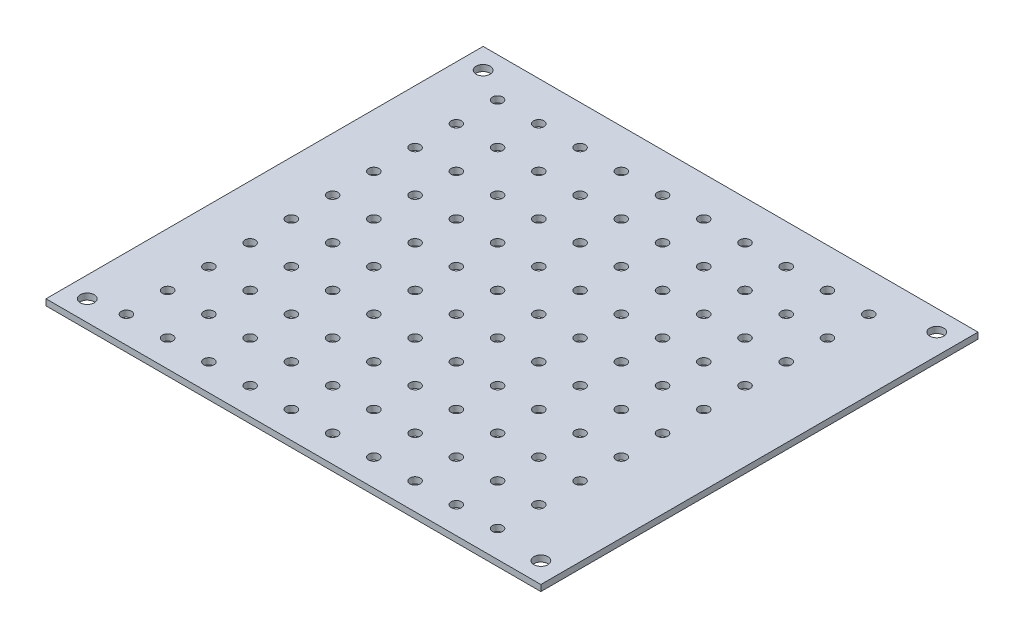
from build123d import *

# Parameters (mm, degrees)
SKETCH1_W           = 120
SKETCH1_H           = 106
SKETCH1_R           = 1.25
SKETCH1_R_2         = 1.7
BOSS_EXTRUDE1_DEPTH = 1.5


with BuildPart() as part:
    # Sketch1 → Boss-Extrude1 (new body)
    with BuildSketch(Plane(origin=(0, 0, 0), x_dir=(1, 0, 0), z_dir=(0, 1, 0))):
        with Locations((60, 53)):
            Rectangle(SKETCH1_W, SKETCH1_H)
        with Locations((13, 36.5)):
            Circle(SKETCH1_R, mode=Mode.SUBTRACT)
        with Locations((23, 36.5)):
            Circle(SKETCH1_R, mode=Mode.SUBTRACT)
        with Locations((13, 6.5)):
            Circle(SKETCH1_R, mode=Mode.SUBTRACT)
        with Locations((5, 5)):
            Circle(SKETCH1_R_2, mode=Mode.SUBTRACT)
        with Locations((5, 101)):
            Circle(SKETCH1_R_2, mode=Mode.SUBTRACT)
        with Locations((115, 101)):
            Circle(SKETCH1_R_2, mode=Mode.SUBTRACT)
        with Locations((115, 5)):
            Circle(SKETCH1_R_2, mode=Mode.SUBTRACT)
        with Locations((23, 6.5)):
            Circle(SKETCH1_R, mode=Mode.SUBTRACT)
        with Locations((33, 6.5)):
            Circle(SKETCH1_R, mode=Mode.SUBTRACT)
        with Locations((23, 16.5)):
            Circle(SKETCH1_R, mode=Mode.SUBTRACT)
        with Locations((33, 16.5)):
            Circle(SKETCH1_R, mode=Mode.SUBTRACT)
        with Locations((23, 26.5)):
            Circle(SKETCH1_R, mode=Mode.SUBTRACT)
        with Locations((33, 26.5)):
            Circle(SKETCH1_R, mode=Mode.SUBTRACT)
        with Locations((13, 16.5)):
            Circle(SKETCH1_R, mode=Mode.SUBTRACT)
        with Locations((13, 26.5)):
            Circle(SKETCH1_R, mode=Mode.SUBTRACT)
        with Locations((33, 36.5)):
            Circle(SKETCH1_R, mode=Mode.SUBTRACT)
        with Locations((13, 46.5)):
            Circle(SKETCH1_R, mode=Mode.SUBTRACT)
        with Locations((23, 46.5)):
            Circle(SKETCH1_R, mode=Mode.SUBTRACT)
        with Locations((33, 46.5)):
            Circle(SKETCH1_R, mode=Mode.SUBTRACT)
        with Locations((13, 56.5)):
            Circle(SKETCH1_R, mode=Mode.SUBTRACT)
        with Locations((23, 56.5)):
            Circle(SKETCH1_R, mode=Mode.SUBTRACT)
        with Locations((33, 56.5)):
            Circle(SKETCH1_R, mode=Mode.SUBTRACT)
        with Locations((13, 66.5)):
            Circle(SKETCH1_R, mode=Mode.SUBTRACT)
        with Locations((23, 66.5)):
            Circle(SKETCH1_R, mode=Mode.SUBTRACT)
        with Locations((33, 66.5)):
            Circle(SKETCH1_R, mode=Mode.SUBTRACT)
        with Locations((13, 76.5)):
            Circle(SKETCH1_R, mode=Mode.SUBTRACT)
        with Locations((23, 76.5)):
            Circle(SKETCH1_R, mode=Mode.SUBTRACT)
        with Locations((33, 76.5)):
            Circle(SKETCH1_R, mode=Mode.SUBTRACT)
        with Locations((13, 86.5)):
            Circle(SKETCH1_R, mode=Mode.SUBTRACT)
        with Locations((23, 86.5)):
            Circle(SKETCH1_R, mode=Mode.SUBTRACT)
        with Locations((33, 86.5)):
            Circle(SKETCH1_R, mode=Mode.SUBTRACT)
        with Locations((13, 96.5)):
            Circle(SKETCH1_R, mode=Mode.SUBTRACT)
        with Locations((23, 96.5)):
            Circle(SKETCH1_R, mode=Mode.SUBTRACT)
        with Locations((33, 96.5)):
            Circle(SKETCH1_R, mode=Mode.SUBTRACT)
        with Locations((43, 6.5)):
            Circle(SKETCH1_R, mode=Mode.SUBTRACT)
        with Locations((53, 6.5)):
            Circle(SKETCH1_R, mode=Mode.SUBTRACT)
        with Locations((63, 6.5)):
            Circle(SKETCH1_R, mode=Mode.SUBTRACT)
        with Locations((73, 6.5)):
            Circle(SKETCH1_R, mode=Mode.SUBTRACT)
        with Locations((83, 6.5)):
            Circle(SKETCH1_R, mode=Mode.SUBTRACT)
        with Locations((93, 6.5)):
            Circle(SKETCH1_R, mode=Mode.SUBTRACT)
        with Locations((103, 6.5)):
            Circle(SKETCH1_R, mode=Mode.SUBTRACT)
        with Locations((43, 16.5)):
            Circle(SKETCH1_R, mode=Mode.SUBTRACT)
        with Locations((53, 16.5)):
            Circle(SKETCH1_R, mode=Mode.SUBTRACT)
        with Locations((63, 16.5)):
            Circle(SKETCH1_R, mode=Mode.SUBTRACT)
        with Locations((73, 16.5)):
            Circle(SKETCH1_R, mode=Mode.SUBTRACT)
        with Locations((83, 16.5)):
            Circle(SKETCH1_R, mode=Mode.SUBTRACT)
        with Locations((93, 16.5)):
            Circle(SKETCH1_R, mode=Mode.SUBTRACT)
        with Locations((103, 16.5)):
            Circle(SKETCH1_R, mode=Mode.SUBTRACT)
        with Locations((43, 26.5)):
            Circle(SKETCH1_R, mode=Mode.SUBTRACT)
        with Locations((53, 26.5)):
            Circle(SKETCH1_R, mode=Mode.SUBTRACT)
        with Locations((63, 26.5)):
            Circle(SKETCH1_R, mode=Mode.SUBTRACT)
        with Locations((73, 26.5)):
            Circle(SKETCH1_R, mode=Mode.SUBTRACT)
        with Locations((83, 26.5)):
            Circle(SKETCH1_R, mode=Mode.SUBTRACT)
        with Locations((93, 26.5)):
            Circle(SKETCH1_R, mode=Mode.SUBTRACT)
        with Locations((103, 26.5)):
            Circle(SKETCH1_R, mode=Mode.SUBTRACT)
        with Locations((43, 36.5)):
            Circle(SKETCH1_R, mode=Mode.SUBTRACT)
        with Locations((53, 36.5)):
            Circle(SKETCH1_R, mode=Mode.SUBTRACT)
        with Locations((63, 36.5)):
            Circle(SKETCH1_R, mode=Mode.SUBTRACT)
        with Locations((73, 36.5)):
            Circle(SKETCH1_R, mode=Mode.SUBTRACT)
        with Locations((83, 36.5)):
            Circle(SKETCH1_R, mode=Mode.SUBTRACT)
        with Locations((93, 36.5)):
            Circle(SKETCH1_R, mode=Mode.SUBTRACT)
        with Locations((103, 36.5)):
            Circle(SKETCH1_R, mode=Mode.SUBTRACT)
        with Locations((43, 46.5)):
            Circle(SKETCH1_R, mode=Mode.SUBTRACT)
        with Locations((53, 46.5)):
            Circle(SKETCH1_R, mode=Mode.SUBTRACT)
        with Locations((63, 46.5)):
            Circle(SKETCH1_R, mode=Mode.SUBTRACT)
        with Locations((73, 46.5)):
            Circle(SKETCH1_R, mode=Mode.SUBTRACT)
        with Locations((83, 46.5)):
            Circle(SKETCH1_R, mode=Mode.SUBTRACT)
        with Locations((93, 46.5)):
            Circle(SKETCH1_R, mode=Mode.SUBTRACT)
        with Locations((103, 46.5)):
            Circle(SKETCH1_R, mode=Mode.SUBTRACT)
        with Locations((43, 56.5)):
            Circle(SKETCH1_R, mode=Mode.SUBTRACT)
        with Locations((53, 56.5)):
            Circle(SKETCH1_R, mode=Mode.SUBTRACT)
        with Locations((63, 56.5)):
            Circle(SKETCH1_R, mode=Mode.SUBTRACT)
        with Locations((73, 56.5)):
            Circle(SKETCH1_R, mode=Mode.SUBTRACT)
        with Locations((83, 56.5)):
            Circle(SKETCH1_R, mode=Mode.SUBTRACT)
        with Locations((93, 56.5)):
            Circle(SKETCH1_R, mode=Mode.SUBTRACT)
        with Locations((103, 56.5)):
            Circle(SKETCH1_R, mode=Mode.SUBTRACT)
        with Locations((43, 66.5)):
            Circle(SKETCH1_R, mode=Mode.SUBTRACT)
        with Locations((53, 66.5)):
            Circle(SKETCH1_R, mode=Mode.SUBTRACT)
        with Locations((63, 66.5)):
            Circle(SKETCH1_R, mode=Mode.SUBTRACT)
        with Locations((73, 66.5)):
            Circle(SKETCH1_R, mode=Mode.SUBTRACT)
        with Locations((83, 66.5)):
            Circle(SKETCH1_R, mode=Mode.SUBTRACT)
        with Locations((93, 66.5)):
            Circle(SKETCH1_R, mode=Mode.SUBTRACT)
        with Locations((103, 66.5)):
            Circle(SKETCH1_R, mode=Mode.SUBTRACT)
        with Locations((43, 76.5)):
            Circle(SKETCH1_R, mode=Mode.SUBTRACT)
        with Locations((53, 76.5)):
            Circle(SKETCH1_R, mode=Mode.SUBTRACT)
        with Locations((63, 76.5)):
            Circle(SKETCH1_R, mode=Mode.SUBTRACT)
        with Locations((73, 76.5)):
            Circle(SKETCH1_R, mode=Mode.SUBTRACT)
        with Locations((83, 76.5)):
            Circle(SKETCH1_R, mode=Mode.SUBTRACT)
        with Locations((93, 76.5)):
            Circle(SKETCH1_R, mode=Mode.SUBTRACT)
        with Locations((103, 76.5)):
            Circle(SKETCH1_R, mode=Mode.SUBTRACT)
        with Locations((43, 86.5)):
            Circle(SKETCH1_R, mode=Mode.SUBTRACT)
        with Locations((53, 86.5)):
            Circle(SKETCH1_R, mode=Mode.SUBTRACT)
        with Locations((63, 86.5)):
            Circle(SKETCH1_R, mode=Mode.SUBTRACT)
        with Locations((73, 86.5)):
            Circle(SKETCH1_R, mode=Mode.SUBTRACT)
        with Locations((83, 86.5)):
            Circle(SKETCH1_R, mode=Mode.SUBTRACT)
        with Locations((93, 86.5)):
            Circle(SKETCH1_R, mode=Mode.SUBTRACT)
        with Locations((103, 86.5)):
            Circle(SKETCH1_R, mode=Mode.SUBTRACT)
        with Locations((43, 96.5)):
            Circle(SKETCH1_R, mode=Mode.SUBTRACT)
        with Locations((53, 96.5)):
            Circle(SKETCH1_R, mode=Mode.SUBTRACT)
        with Locations((63, 96.5)):
            Circle(SKETCH1_R, mode=Mode.SUBTRACT)
        with Locations((73, 96.5)):
            Circle(SKETCH1_R, mode=Mode.SUBTRACT)
        with Locations((83, 96.5)):
            Circle(SKETCH1_R, mode=Mode.SUBTRACT)
        with Locations((93, 96.5)):
            Circle(SKETCH1_R, mode=Mode.SUBTRACT)
        with Locations((103, 96.5)):
            Circle(SKETCH1_R, mode=Mode.SUBTRACT)
    extrude(amount=BOSS_EXTRUDE1_DEPTH)


solid = part.part
